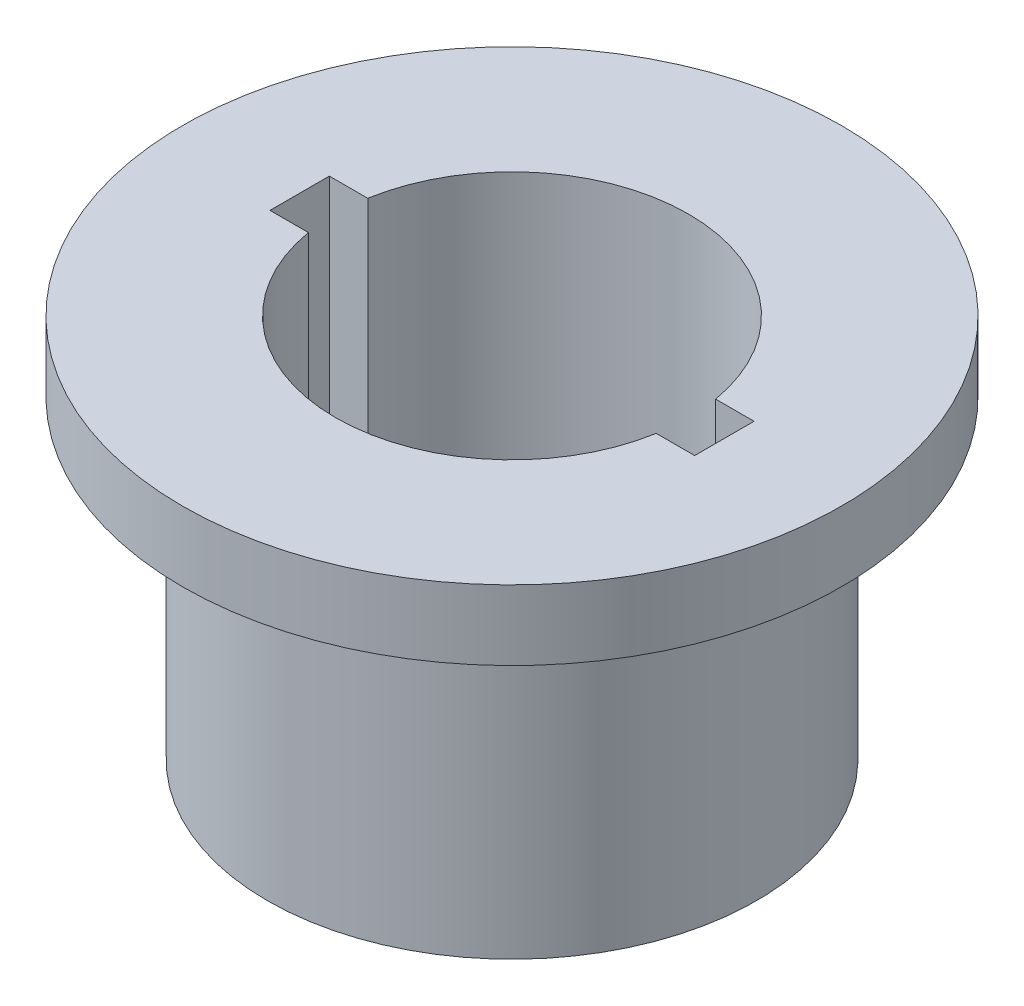
from build123d import *

# Parameters (mm, degrees)
SKETCH1_R           = 7
BOSS_EXTRUDE1_DEPTH = 11
SKETCH2_R           = 9.433087352
SKETCH2_R_2         = 7
BOSS_EXTRUDE2_DEPTH = 2


with BuildPart() as part:
    # Sketch1 → Boss-Extrude1 (new body)
    with BuildSketch(Plane(origin=(0, 0, 0), x_dir=(1, 0, 0), z_dir=(0, 1, 0))):
        Circle(SKETCH1_R)
        with BuildLine():
            Line((-6.077951386, 0.85), (-4.977951386, 0.85))
            ThreePointArc((-4.977951386, 0.85), (0, 5.05), (4.977951386, 0.85))
            Line((4.977951386, 0.85), (6.077951386, 0.85))
            Line((6.077951386, 0.85), (6.077951386, -0.85))
            Line((6.077951386, -0.85), (4.977951386, -0.85))
            ThreePointArc((4.977951386, -0.85), (0, -5.05), (-4.977951386, -0.85))
            Line((-4.977951386, -0.85), (-6.077951386, -0.85))
            Line((-6.077951386, -0.85), (-6.077951386, 0.85))
        make_face(mode=Mode.SUBTRACT)
    extrude(amount=BOSS_EXTRUDE1_DEPTH)

    # Sketch2 → Boss-Extrude2 (add)
    with BuildSketch(Plane(origin=(0, 11, 0), x_dir=(1, 0, 0), z_dir=(0, 1, 0))):
        Circle(SKETCH2_R)
        Circle(SKETCH2_R_2, mode=Mode.SUBTRACT)
    extrude(amount=-BOSS_EXTRUDE2_DEPTH)


solid = part.part
